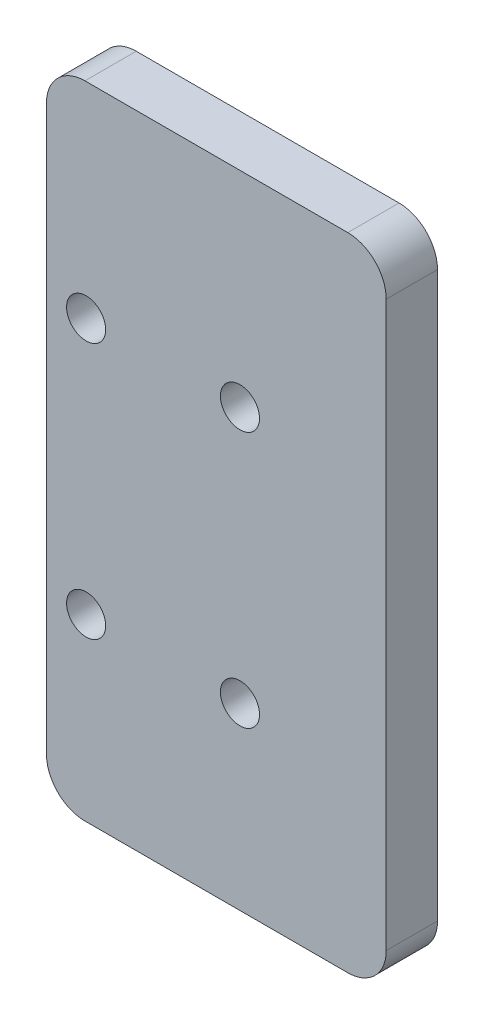
from build123d import *

# Parameters (mm, degrees)
SKETCH_1_W          = 26.5
SKETCH_1_H          = 50
EXTRUDE_1_DEPTH     = 4
SKETCH_2_R          = 1.525
CUT_EXTRUDE_1_DEPTH = 4
FILLET_1_R          = 3


with BuildPart() as part:
    # 草图1 → 凸台-拉伸1 (new body)
    with BuildSketch(Plane.XY):
        Rectangle(SKETCH_1_W, SKETCH_1_H)
    extrude(amount=EXTRUDE_1_DEPTH)

    # 草图2 → 切除-拉伸1 (cut)
    with BuildSketch(Plane.XY.offset(4)):
        with Locations((-10.158640444, 9)):
            Circle(SKETCH_2_R)
        with Locations((1.841359556, 9)):
            Circle(SKETCH_2_R)
        with Locations((-10.158640444, -11)):
            Circle(SKETCH_2_R)
        with Locations((1.841359556, -11)):
            Circle(SKETCH_2_R)
    extrude(amount=-CUT_EXTRUDE_1_DEPTH, mode=Mode.SUBTRACT)

    # 圆角1
    fillet_1_edges = [part.edges().sort_by_distance(p)[0] for p in [
        (13.25, -25, 2),
        (-13.25, -25, 2),
        (-13.25, 25, 2),
        (13.25, 25, 2),
    ]]
    fillet(fillet_1_edges, radius=FILLET_1_R)


solid = part.part
